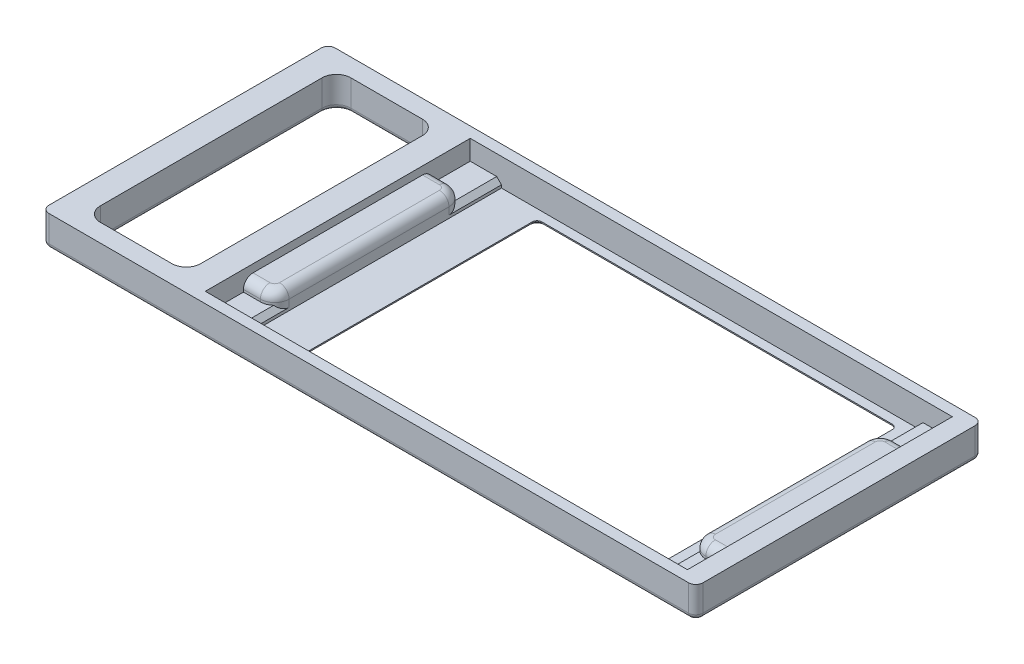
from build123d import *

# Parameters (mm, degrees)
SKETCH1_W           = 137
SKETCH1_H           = 60
BOSS_EXTRUDE1_DEPTH = 6.5
SKETCH2_W           = 101
SKETCH2_H           = 55.5
CUT_EXTRUDE1_DEPTH  = 1.65
SKETCH3_W           = 87.3
SKETCH3_H           = 55.5
CUT_EXTRUDE2_DEPTH  = 4.1
SKETCH4_W           = 75.4
SKETCH4_H           = 51.7
CUT_EXTRUDE3_DEPTH  = 1.75
FILLET1_R           = 1
SKETCH6_W           = 7.15
SKETCH6_H           = 8
SKETCH6_W_2         = 6.55
CUT_EXTRUDE4_DEPTH  = 2.5
FILLET2_R           = 3
CHAMFER1_SIZE       = 0.5
SKETCH7_W           = 21
SKETCH7_H           = 52.453625608
CUT_EXTRUDE5_DEPTH  = 7.5
FILLET3_R           = 3
FILLET5_R           = 2
CHAMFER3_SIZE       = 1
FILLET6_R           = 1.5
FILLET7_R           = 1


with BuildPart() as part:
    # Sketch1 → Boss-Extrude1 (new body)
    with BuildSketch(Plane(origin=(0, 0, 0), x_dir=(1, 0, 0), z_dir=(0, 1, 0))):
        Rectangle(SKETCH1_W, SKETCH1_H)
    extrude(amount=BOSS_EXTRUDE1_DEPTH)

    # Sketch2 → Cut-Extrude1 (cut)
    with BuildSketch(Plane(origin=(0, 6.5, 0), x_dir=(1, 0, 0), z_dir=(0, 1, 0))):
        with Locations((14, 0)):
            Rectangle(SKETCH2_W, SKETCH2_H)
    extrude(amount=-CUT_EXTRUDE1_DEPTH, mode=Mode.SUBTRACT)

    # Sketch3 → Cut-Extrude2 (cut)
    with BuildSketch(Plane(origin=(0, 4.85, 0), x_dir=(1, 0, 0), z_dir=(0, 1, 0))):
        with Locations((13.7, 0)):
            Rectangle(SKETCH3_W, SKETCH3_H)
    extrude(amount=-CUT_EXTRUDE2_DEPTH, mode=Mode.SUBTRACT)

    # Sketch4 → Cut-Extrude3 (cut, through all)
    with BuildSketch(Plane(origin=(0, 0.75, 0), x_dir=(1, 0, 0), z_dir=(0, 1, 0))):
        with Locations((17.1, 0)):
            Rectangle(SKETCH4_W, SKETCH4_H)
    extrude(amount=-CUT_EXTRUDE3_DEPTH, mode=Mode.SUBTRACT)

    # Fillet1
    fillet1_edges = [part.edges().sort_by_distance(p)[0] for p in [
        (54.8, 0.375, -25.85),
        (54.8, 0.375, 25.85),
        (-20.6, 0.375, 25.85),
        (-20.6, 0.375, -25.85),
    ]]
    fillet(fillet1_edges, radius=FILLET1_R)

    # Sketch6 → Cut-Extrude4 (cut)
    with BuildSketch(Plane(origin=(0, 4.85, 0), x_dir=(1, 0, 0), z_dir=(0, 1, 0))):
        with Locations((60.925, -23.75)):
            Rectangle(SKETCH6_W, SKETCH6_H)
        with Locations((60.925, 23.75)):
            Rectangle(SKETCH6_W, SKETCH6_H)
        with Locations((-33.225, 23.75)):
            Rectangle(SKETCH6_W_2, SKETCH6_H)
        with Locations((-33.225, -23.75)):
            Rectangle(SKETCH6_W_2, SKETCH6_H)
    extrude(amount=-CUT_EXTRUDE4_DEPTH, mode=Mode.SUBTRACT)

    # Fillet2
    fillet2_edges = [part.edges().sort_by_distance(p)[0] for p in [
        (-29.95, 3.6, 19.75),
        (-29.95, 3.6, -19.75),
        (57.35, 3.6, -19.75),
        (57.35, 3.6, 19.75),
    ]]
    fillet(fillet2_edges, radius=FILLET2_R)

    # Chamfer1
    chamfer1_edges = [part.edges().sort_by_distance(p)[0] for p in [
        (17.1, 0, -25.85),
        (54.8, 0, 0),
        (17.1, 0, 25.85),
        (-20.6, 0, 0),
        (54.507106781, 0, -25.557106781),
        (54.507106781, 0, 25.557106781),
        (-20.307106781, 0, 25.557106781),
        (-20.307106781, 0, -25.557106781),
    ]]
    chamfer(chamfer1_edges, length=CHAMFER1_SIZE)

    # Sketch7 → Cut-Extrude5 (cut, through all)
    with BuildSketch(Plane(origin=(0, 6.5, 0), x_dir=(1, 0, 0), z_dir=(0, 1, 0))):
        with Locations((-52.5, 0)):
            Rectangle(SKETCH7_W, SKETCH7_H)
    extrude(amount=-CUT_EXTRUDE5_DEPTH, mode=Mode.SUBTRACT)

    # Fillet3
    fillet3_edges = [part.edges().sort_by_distance(p)[0] for p in [
        (-42, 3.25, -26.226812804),
        (-42, 3.25, 26.226812804),
        (-63, 3.25, 26.226812804),
        (-63, 3.25, -26.226812804),
    ]]
    fillet(fillet3_edges, radius=FILLET3_R)

    # Fillet5
    fillet5_edges = [part.edges().sort_by_distance(p)[0] for p in [
        (-34.725, 4.85, -19.75),
        (62.425, 4.85, 19.75),
        (62.425, 4.85, -19.75),
        (57.35, 4.85, 0),
        (58.228679656, 4.85, 18.871320344),
        (58.228679656, 4.85, -18.871320344),
        (-34.725, 4.85, 19.75),
        (-29.95, 4.85, 0),
        (-30.828679656, 4.85, -18.871320344),
        (-30.828679656, 4.85, 18.871320344),
    ]]
    fillet(fillet5_edges, radius=FILLET5_R)

    # Chamfer3
    chamfer3_edges = [part.edges().sort_by_distance(p)[0] for p in [
        (-29.95, 2.35, 22.25),
        (-29.95, 2.35, -22.25),
        (57.35, 2.35, -22.25),
        (57.35, 2.35, 22.25),
    ]]
    chamfer(chamfer3_edges, length=CHAMFER3_SIZE)

    # Fillet6
    fillet6_edges = [part.edges().sort_by_distance(p)[0] for p in [
        (68.5, 3.25, 30),
        (-68.5, 3.25, 30),
        (-68.5, 3.25, -30),
        (68.5, 3.25, -30),
    ]]
    fillet(fillet6_edges, radius=FILLET6_R)

    # Fillet7
    fillet7_edges = [part.edges().sort_by_distance(p)[0] for p in [
        (-42, 0, 0),
        (-52.5, 0, 26.226812804),
        (-63, 0, 0),
        (-52.5, 0, -26.226812804),
        (-42.878679656, 0, 25.348133148),
        (-62.121320344, 0, 25.348133148),
        (-62.121320344, 0, -25.348133148),
        (-42.878679656, 0, -25.348133148),
        (68.5, 0, 0),
        (0, 0, 30),
        (-68.5, 0, 0),
        (0, 0, -30),
        (68.060660172, 0, -29.560660172),
        (-68.060660172, 0, -29.560660172),
        (-68.060660172, 0, 29.560660172),
        (68.060660172, 0, 29.560660172),
    ]]
    fillet(fillet7_edges, radius=FILLET7_R)


solid = part.part
